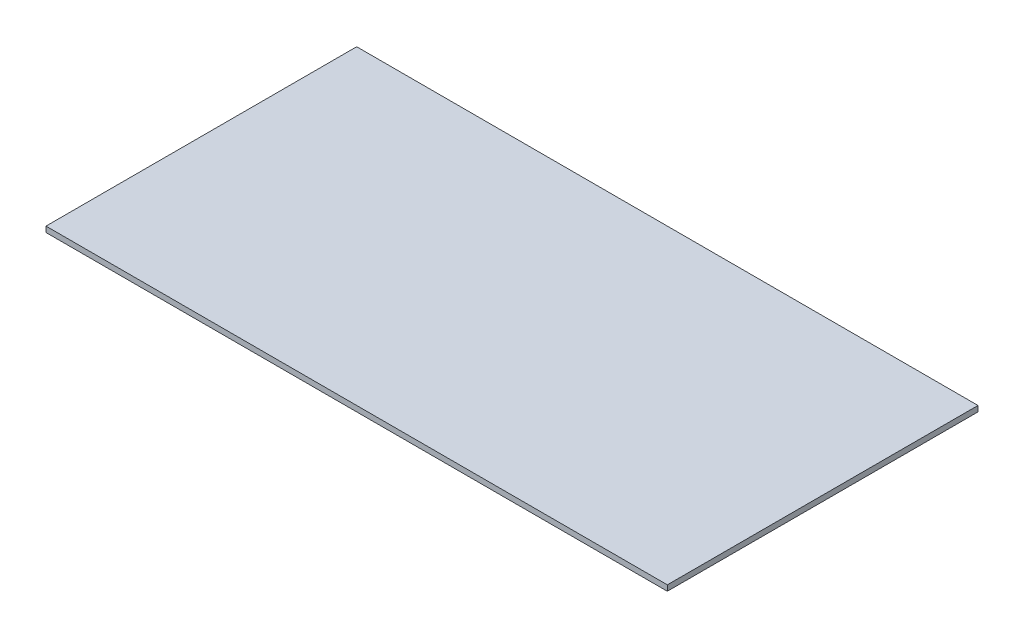
from build123d import *

# Parameters (mm, degrees)
SKETCH1_W           = 50
SKETCH1_H           = 25
BOSS_EXTRUDE1_DEPTH = 0.45


with BuildPart() as part:
    # Sketch1 → Boss-Extrude1 (new body)
    with BuildSketch(Plane(origin=(0, 0, 0), x_dir=(1, 0, 0), z_dir=(0, 1, 0))):
        with Locations((25, 12.5)):
            Rectangle(SKETCH1_W, SKETCH1_H)
    extrude(amount=BOSS_EXTRUDE1_DEPTH)


solid = part.part
